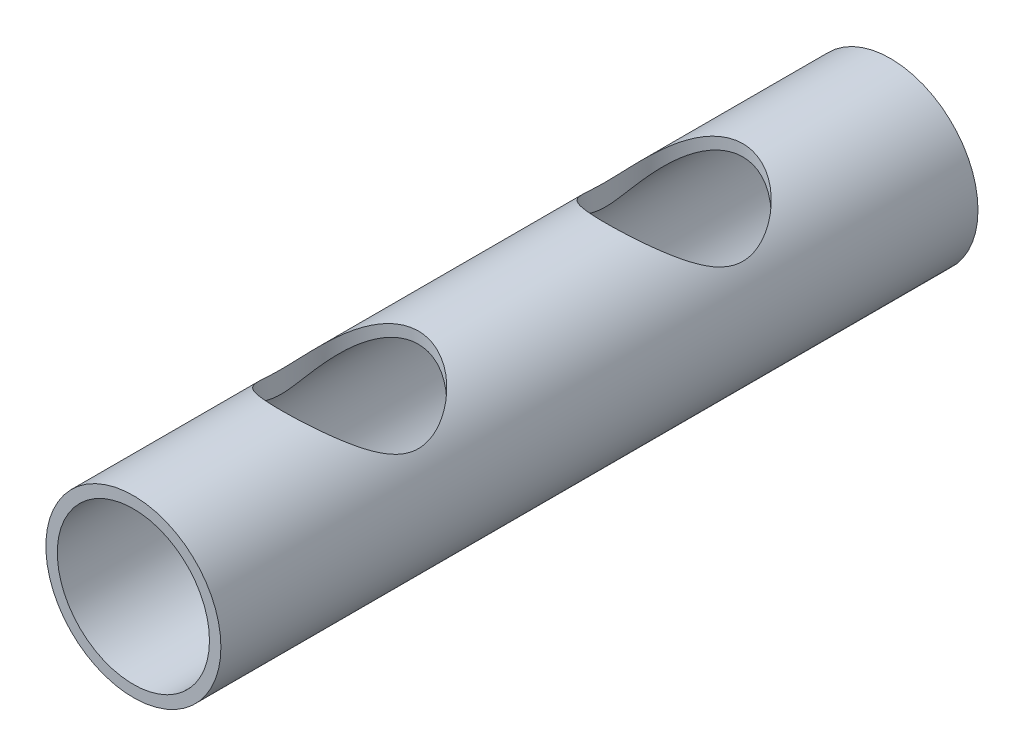
from build123d import *

# Parameters (mm, degrees)
SKETCH1_R           = 24.28
SKETCH1_R_2         = 21.105
BOSS_EXTRUDE1_DEPTH = 210
SKETCH2_R           = 19.05
CUT_EXTRUDE1_DEPTH  = 100


with BuildPart() as part:
    # Sketch1 → Boss-Extrude1 (new body)
    with BuildSketch(Plane.XY):
        Circle(SKETCH1_R)
        Circle(SKETCH1_R_2, mode=Mode.SUBTRACT)
    extrude(amount=BOSS_EXTRUDE1_DEPTH)

    # Sketch2 → Cut-Extrude1 (cut)
    with BuildSketch(Plane(origin=(0, 0, 0), x_dir=(1, 0, 0), z_dir=(0, 1, 0))):
        with Locations((0, -150)):
            Circle(SKETCH2_R)
        with Locations((0, -60)):
            Circle(SKETCH2_R)
    extrude(amount=CUT_EXTRUDE1_DEPTH, mode=Mode.SUBTRACT)


solid = part.part
